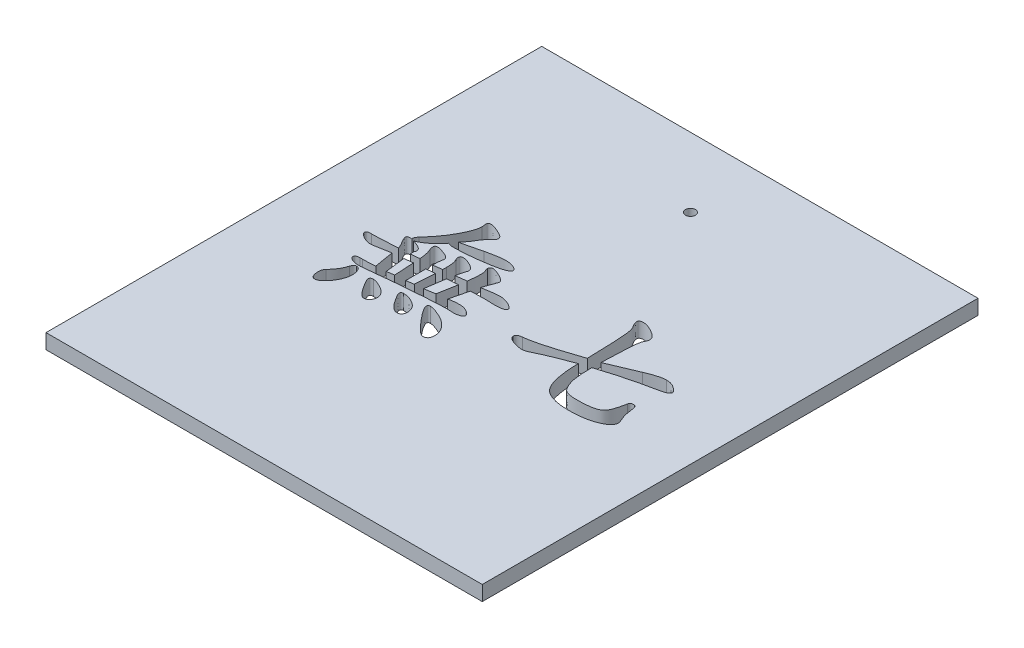
from build123d import *

# Parameters (mm, degrees)
SKETCH_1_W          = 44
SKETCH_1_H          = 1.5
EXTRUDE_1_DEPTH     = 50
CUT_EXTRUDE_1_DEPTH = 50
SKETCH_4_R          = 0.5
CUT_EXTRUDE_2_DEPTH = 1.5


with BuildPart() as part:
    # 草图1 → 凸台-拉伸1 (new body)
    with BuildSketch(Plane.XY):
        with Locations((-14.28686933, 29.867045997)):
            Rectangle(SKETCH_1_W, SKETCH_1_H)
    extrude(amount=EXTRUDE_1_DEPTH)

    # 草图3 → 切除-拉伸1 (cut)
    with BuildSketch(Plane(origin=(0, 30.617045997, 0), x_dir=(1, 0, 0), z_dir=(0, 1, 0))):
        with BuildLine():
            add(Edge.make_bspline(
                [(-23.405861887, -21.298851129), (-23.380420031, -21.296850924), (-23.312187575, -21.291486578), (-23.183397047, -21.268497079), (-23.002345834, -21.22778541), (-22.76637734, -21.175455687), (-22.477116994, -21.105205228), (-22.134721806, -21.019720235), (-21.737716997, -20.920880577), (-21.456447551, -20.846550118), (-21.306421105, -20.806902959)],
                knots=[0, 0, 0, 0, 7.6532e-05, 0.00020525, 0.000391886, 0.000633382, 0.000930282, 0.001284867, 0.001692106, 0.00215763, 0.00215763, 0.00215763, 0.00215763], degree=3))
            add(Edge.make_bspline(
                [(-21.306421105, -20.806902959), (-21.200310189, -20.782416227), (-20.996209601, -20.735316867), (-20.700555065, -20.677482905), (-20.430325523, -20.621646895), (-20.183281135, -20.582261706), (-19.961322919, -20.545167944), (-19.76312991, -20.522840732), (-19.589074754, -20.507970815), (-19.39247369, -20.501740726), (-19.172856504, -20.511554553), (-18.930074038, -20.54353493), (-18.70967313, -20.594402951), (-18.517566744, -20.67059639), (-18.359821831, -20.755796559), (-18.239155443, -20.839293983), (-18.159969986, -20.93037116), (-18.147696835, -20.998414248), (-18.142247429, -21.028626078)],
                knots=[0, 0, 0, 0, 0.00032667, 0.000628338, 0.000903735, 0.001154336, 0.001378749, 0.001578715, 0.001752489, 0.001902685, 0.002168542, 0.002410909, 0.002636661, 0.002845103, 0.003029062, 0.003172723, 0.003286365, 0.003377118, 0.003377118, 0.003377118, 0.003377118], degree=3))
            add(Edge.make_bspline(
                [(-18.142247429, -21.028626078), (-18.149339207, -21.063231783), (-18.165256083, -21.140901268), (-18.270661513, -21.237505185), (-18.422318487, -21.326546677), (-18.634570353, -21.412363253), (-18.902404858, -21.496405634), (-19.230775847, -21.575744969), (-19.617485574, -21.653532635), (-20.05080231, -21.724065837), (-20.501000476, -21.787068312), (-20.94009763, -21.849716358), (-21.355551939, -21.895964632), (-21.746280851, -21.940108062), (-22.113102868, -21.968358218), (-22.455599241, -21.992675149), (-22.773670411, -22.007167311), (-22.977800319, -22.00922641), (-23.075586825, -22.010212802)],
                knots=[0, 0, 0, 0, 0.000103753, 0.000232864, 0.000409138, 0.000634772, 0.000915986, 0.001251525, 0.001647407, 0.002099249, 0.002568288, 0.003011205, 0.003429755, 0.003822288, 0.004190743, 0.004533345, 0.004852373, 0.005145731, 0.005145731, 0.005145731, 0.005145731], degree=3))
            add(Edge.make_bspline(
                [(-23.075586825, -22.010212802), (-23.158166436, -22.009896263), (-23.309163641, -22.009317469), (-23.510545672, -21.981508182), (-23.672087695, -21.95287465), (-23.753808704, -21.905879412), (-23.789258114, -21.885493548)],
                knots=[0, 0, 0, 0, 0.000247226, 0.000452054, 0.000611149, 0.000733035, 0.000733035, 0.000733035, 0.000733035], degree=3))
            add(Edge.make_bspline(
                [(-23.789258114, -21.885493548), (-23.867134405, -21.98673215), (-24.023435674, -22.18992264), (-24.285062466, -22.475321696), (-24.576169422, -22.738583583), (-24.834024926, -22.940921254), (-25.042488924, -23.08933111), (-25.190534931, -23.183517598), (-25.326730523, -23.264655409), (-25.450806356, -23.332494465), (-25.565136501, -23.38429639), (-25.6686581, -23.420896391), (-25.761169619, -23.447002515), (-25.82004213, -23.450023365), (-25.847125811, -23.451413075)],
                knots=[0, 0, 0, 0, 0.000383069, 0.000768837, 0.001159572, 0.001559242, 0.001751482, 0.001927028, 0.002085469, 0.002227035, 0.00235109, 0.002461396, 0.002556624, 0.002637757, 0.002637757, 0.002637757, 0.002637757], degree=3))
            add(Edge.make_bspline(
                [(-25.847125811, -23.451413075), (-25.875950013, -23.449571911), (-25.928254145, -23.446230953), (-25.997455747, -23.413467254), (-26.039172493, -23.352381248), (-26.046878344, -23.272372289), (-26.032690919, -23.178857214), (-25.984930733, -23.077534097), (-25.914447158, -22.966554718), (-25.851427804, -22.896176968), (-25.817100805, -22.857841809)],
                knots=[0, 0, 0, 0, 8.6233e-05, 0.000156477, 0.000221187, 0.000298274, 0.000391693, 0.000502386, 0.000631166, 0.000785237, 0.000785237, 0.000785237, 0.000785237], degree=3))
            add(Edge.make_bspline(
                [(-25.817100805, -22.857841809), (-25.646255372, -22.665745266), (-25.312356797, -22.290313739), (-24.861508084, -21.709061797), (-24.472023846, -21.126210772), (-24.190256392, -20.641108612), (-24.00264455, -20.259829081), (-23.875412114, -19.997477417), (-23.772715387, -19.750029411), (-23.684793572, -19.521442509), (-23.621524942, -19.308438378), (-23.570888654, -19.114972192), (-23.541490843, -18.937790792), (-23.537220937, -18.825342908), (-23.535200373, -18.77213142)],
                knots=[0, 0, 0, 0, 0.000771097, 0.001507024, 0.002204608, 0.00287295, 0.003187982, 0.003479323, 0.003747418, 0.003991517, 0.004213625, 0.004413603, 0.004591309, 0.00475094, 0.00475094, 0.00475094, 0.00475094], degree=3))
            add(Edge.make_bspline(
                [(-23.535200373, -18.77213142), (-23.53664253, -18.745822575), (-23.539725466, -18.689581472), (-23.565673208, -18.595297532), (-23.579107561, -18.464428887), (-23.589510539, -18.333628792), (-23.574431008, -18.210933949), (-23.507627429, -18.135280619), (-23.400596373, -18.103321763), (-23.262695526, -18.089683074), (-23.08397472, -18.112119861), (-22.865684425, -18.173718742), (-22.604579074, -18.272844337), (-22.366621669, -18.380167617), (-22.170715564, -18.476884709), (-22.038117078, -18.550956519), (-21.925911447, -18.622330314), (-21.831146823, -18.687518286), (-21.760674762, -18.755834401), (-21.709950669, -18.820329408), (-21.672319922, -18.881409908), (-21.662363544, -18.964385958), (-21.680639618, -19.066507304), (-21.741246767, -19.184653809), (-21.832273839, -19.307086891), (-21.915220183, -19.37812627), (-21.960042383, -19.416514234)],
                knots=[0, 0, 0, 0, 7.8832e-05, 0.000168521, 0.000291994, 0.000472277, 0.000564228, 0.000652659, 0.000756464, 0.000891136, 0.001067637, 0.001292288, 0.001570719, 0.001904656, 0.002075083, 0.002226058, 0.002359976, 0.002474086, 0.002570456, 0.002652699, 0.002720901, 0.002781657, 0.002898607, 0.003026702, 0.003176827, 0.003353328, 0.003353328, 0.003353328, 0.003353328], degree=3))
            add(Edge.make_bspline(
                [(-21.960042383, -19.416514234), (-22.020669495, -19.472977798), (-22.148169024, -19.591721336), (-22.321051397, -19.805694727), (-22.497796293, -20.04988152), (-22.663106901, -20.32563997), (-22.830364383, -20.605386037), (-23.014698208, -20.862049182), (-23.202064553, -21.095156806), (-23.339196024, -21.232218962), (-23.405861887, -21.298851129)],
                knots=[0, 0, 0, 0, 0.00024826, 0.000522093, 0.000823336, 0.00115213, 0.001486067, 0.001800735, 0.002099417, 0.002381994, 0.002381994, 0.002381994, 0.002381994], degree=3))
        make_face()
        with BuildLine():
            add(Edge.make_bspline(
                [(-19.548803465, -24.255159381), (-19.532952641, -24.146675791), (-19.502536415, -23.938506091), (-19.466039455, -23.638397458), (-19.448460977, -23.363099872), (-19.440779726, -23.11503416), (-19.444312885, -22.898277878), (-19.459348098, -22.716783619), (-19.484753723, -22.571979493), (-19.532530067, -22.43654721), (-19.598204605, -22.312288874), (-19.608863999, -22.211041933), (-19.613472708, -22.167266678)],
                knots=[0, 0, 0, 0, 0.000328916, 0.000631158, 0.000906622, 0.001156157, 0.001375619, 0.001556493, 0.001702347, 0.001814833, 0.001986818, 0.002117816, 0.002117816, 0.002117816, 0.002117816], degree=3))
            add(Edge.make_bspline(
                [(-19.613472708, -22.167266678), (-19.610891854, -22.121892461), (-19.606238765, -22.040086088), (-19.549652739, -21.933098495), (-19.450851526, -21.86994858), (-19.318091439, -21.856899197), (-19.153126392, -21.879406802), (-18.94849865, -21.941409335), (-18.702423786, -22.039242977), (-18.478407841, -22.148217875), (-18.292664392, -22.243685869), (-18.166650993, -22.31797158), (-18.059670562, -22.390682323), (-17.973833514, -22.465181233), (-17.905504298, -22.536591265), (-17.855474223, -22.606699409), (-17.82223424, -22.67645188), (-17.81840196, -22.724352224), (-17.816591599, -22.746980249)],
                knots=[0, 0, 0, 0, 0.000135226, 0.000243802, 0.000348858, 0.000472655, 0.00063538, 0.000846669, 0.001112154, 0.001429312, 0.001593571, 0.001738545, 0.001867966, 0.001980948, 0.002078991, 0.002163569, 0.002239083, 0.002306696, 0.002306696, 0.002306696, 0.002306696], degree=3))
            add(Edge.make_bspline(
                [(-17.816591599, -22.746980249), (-17.821916814, -22.774942125), (-17.83386715, -22.837691475), (-17.858413938, -22.896716915), (-17.872022378, -22.929439899)],
                knots=[0, 0, 0, 0, 8.5174e-05, 0.00019114, 0.00019114, 0.00019114, 0.00019114], degree=3))
            add(Edge.make_bspline(
                [(-17.872022378, -22.929439899), (-17.907257113, -23.016981509), (-17.981324183, -23.201003064), (-18.085371784, -23.494721863), (-18.198247982, -23.815387178), (-18.267762958, -24.040871769), (-18.303920537, -24.158155516)],
                knots=[0, 0, 0, 0, 0.000283067, 0.000595036, 0.000934675, 0.001302825, 0.001302825, 0.001302825, 0.001302825], degree=3))
            add(Edge.make_bspline(
                [(-18.303920537, -24.158155516), (-18.213906044, -24.140134193), (-18.038747598, -24.10506665), (-17.783784974, -24.05939763), (-17.54440202, -24.01975304), (-17.322050959, -23.986441008), (-17.115327868, -23.964951993), (-16.92544107, -23.943965127), (-16.751137523, -23.936633879), (-16.542402346, -23.928256946), (-16.297047259, -23.941649035), (-16.016272229, -23.992396207), (-15.749315157, -24.07657804), (-15.506807311, -24.188726313), (-15.300918487, -24.311129622), (-15.149158376, -24.423348064), (-15.0396266, -24.519055974), (-15.020489933, -24.594185633), (-15.012717991, -24.624697912)],
                knots=[0, 0, 0, 0, 0.000275397, 0.000535892, 0.000777001, 0.001003355, 0.001210205, 0.001400492, 0.001576266, 0.001733388, 0.002027154, 0.0023112, 0.002587312, 0.002864283, 0.003111843, 0.003301696, 0.003437336, 0.003530095, 0.003530095, 0.003530095, 0.003530095], degree=3))
            add(Edge.make_bspline(
                [(-15.012717991, -24.624697912), (-15.016469248, -24.652582209), (-15.024170226, -24.709826052), (-15.085851908, -24.783203216), (-15.17841432, -24.8397297), (-15.303665874, -24.887892829), (-15.464918579, -24.922165711), (-15.66016159, -24.949316932), (-15.890897835, -24.964871631), (-16.055871659, -24.965944914), (-16.144429744, -24.966521054)],
                knots=[0, 0, 0, 0, 8.2921e-05, 0.00017023, 0.000275285, 0.000406954, 0.000570546, 0.00076881, 0.000998033, 0.001263679, 0.001263679, 0.001263679, 0.001263679], degree=3))
            Line((-16.144429744, -24.966521054), (-17.098301078, -24.936496048))
            add(Edge.make_bspline(
                [(-17.098301078, -24.936496048), (-17.200697454, -24.9369836), (-17.415519423, -24.938006457), (-17.752741509, -24.945465461), (-18.120758672, -24.956968868), (-18.376298104, -24.967803348), (-18.509476345, -24.973449901)],
                knots=[0, 0, 0, 0, 0.000307188, 0.000644463, 0.001011873, 0.001411764, 0.001411764, 0.001411764, 0.001411764], degree=3))
            Line((-18.509476345, -24.973449901), (-18.964470662, -26.828071406))
            add(Edge.make_bspline(
                [(-18.964470662, -26.828071406), (-18.883948938, -26.805949739), (-18.721250947, -26.761251854), (-18.467618602, -26.718086665), (-18.205139993, -26.694195146), (-17.938113035, -26.682543258), (-17.675636452, -26.69827079), (-17.42706606, -26.739633724), (-17.199630567, -26.816792742), (-17.001161215, -26.921900614), (-16.836745389, -27.035799307), (-16.712534846, -27.146554774), (-16.63158692, -27.251988391), (-16.603140752, -27.358688707), (-16.625143289, -27.458382695), (-16.700804214, -27.537500586), (-16.810004463, -27.607440706), (-17.00891576, -27.672831977), (-17.273984879, -27.73193018), (-17.590128006, -27.737296571), (-17.880849106, -27.70844898), (-18.068264825, -27.708169479), (-18.15841474, -27.708035034)],
                knots=[0, 0, 0, 0, 0.000250399, 0.000505943, 0.000770462, 0.001040845, 0.001306943, 0.001557937, 0.00179458, 0.002023919, 0.002229592, 0.002393037, 0.002522458, 0.002622173, 0.002714616, 0.002814572, 0.002941411, 0.003101443, 0.003438908, 0.003753151, 0.004044749, 0.004315013, 0.004315013, 0.004315013, 0.004315013], degree=3))
            add(Edge.make_bspline(
                [(-18.15841474, -27.708035034), (-18.24156694, -27.708438532), (-18.424083298, -27.709324198), (-18.720529838, -27.719368458), (-19.063834267, -27.736305491), (-19.454146346, -27.757360358), (-19.892403554, -27.78136466), (-20.377202836, -27.817942666), (-20.908448026, -27.856698304), (-21.471242537, -27.899607467), (-22.037199554, -27.943875519), (-22.576617116, -27.991680253), (-23.075760796, -28.031661858), (-23.533087598, -28.073216139), (-23.948712319, -28.115185201), (-24.323649828, -28.154391831), (-24.657806493, -28.191115704), (-24.954206339, -28.225835729), (-25.217976289, -28.259877899), (-25.456125158, -28.286125045), (-25.670512247, -28.313800062), (-25.862589535, -28.330104995), (-26.031630873, -28.348827035), (-26.178178385, -28.356169199), (-26.302035731, -28.364414873), (-26.495102585, -28.369352893), (-26.769682365, -28.343054258), (-27.054433444, -28.255070603), (-27.256261902, -28.16160023), (-27.368033832, -28.084446117), (-27.443707622, -28.001210287), (-27.464292725, -27.907038624), (-27.453003909, -27.826301151), (-27.429977838, -27.756034089), (-27.381952111, -27.70321983), (-27.290898789, -27.661289315), (-27.155328957, -27.633078214), (-27.04133921, -27.629230341), (-26.981147179, -27.627198481)],
                knots=[0, 0, 0, 0, 0.000249449, 0.000547533, 0.000889738, 0.001280616, 0.001720178, 0.002206433, 0.002739094, 0.003318163, 0.003899714, 0.004442134, 0.004942741, 0.00540193, 0.005819735, 0.006195947, 0.006532874, 0.006828234, 0.007091216, 0.007330715, 0.007547007, 0.007739594, 0.007908969, 0.008057073, 0.008179678, 0.008281328, 0.008636393, 0.009000969, 0.009170375, 0.009301129, 0.009407897, 0.009498091, 0.009579453, 0.009651089, 0.009716496, 0.00978674, 0.009948083, 0.010128603, 0.010128603, 0.010128603, 0.010128603], degree=3))
            Line((-26.981147179, -27.627198481), (-26.71554136, -27.627198481))
            add(Edge.make_bspline(
                [(-26.71554136, -27.627198481), (-26.623908615, -27.626268662), (-26.432080458, -27.624322136), (-26.132611385, -27.608745416), (-25.808322155, -27.58897068), (-25.584553509, -27.568526709), (-25.468348816, -27.557910006)],
                knots=[0, 0, 0, 0, 0.000274883, 0.000575453, 0.000899466, 0.001249509, 0.001249509, 0.001249509, 0.001249509], degree=3))
            Line((-25.468348816, -27.557910006), (-25.791695031, -25.594736557))
            add(Edge.make_bspline(
                [(-25.791695031, -25.594736557), (-25.918051343, -25.613397041), (-26.154098205, -25.648256783), (-26.483140771, -25.705654759), (-26.764474324, -25.752742599), (-27.000134093, -25.807657409), (-27.205050695, -25.851955568), (-27.391635195, -25.882150447), (-27.565825188, -25.900384841), (-27.732769721, -25.911060013), (-27.905055042, -25.893305067), (-28.090178048, -25.845054803), (-28.295462916, -25.7664247), (-28.50818107, -25.664249394), (-28.70259581, -25.550313784), (-28.853431398, -25.438343496), (-28.950689828, -25.330386761), (-28.985078208, -25.221631145), (-28.976169871, -25.133764777), (-28.953636245, -25.065148093), (-28.915403861, -25.012890982), (-28.828788761, -24.978183461), (-28.684653901, -24.965391454), (-28.560152926, -24.963193171), (-28.487016695, -24.961901822)],
                knots=[0, 0, 0, 0, 0.000383153, 0.000715769, 0.001002087, 0.001238572, 0.001441503, 0.001630976, 0.00180518, 0.001967001, 0.002131779, 0.002322235, 0.002539302, 0.002790329, 0.003029572, 0.003213908, 0.003353501, 0.003457254, 0.003545292, 0.003613962, 0.003673117, 0.003732001, 0.003886175, 0.004105698, 0.004105698, 0.004105698, 0.004105698], degree=3))
            add(Edge.make_bspline(
                [(-28.487016695, -24.961901822), (-28.419262203, -24.961418959), (-28.272175647, -24.960370723), (-28.034321967, -24.952109245), (-27.761725441, -24.943767196), (-27.454550932, -24.929343766), (-27.112709992, -24.911020021), (-26.736341397, -24.887001707), (-26.325121801, -24.862516343), (-26.039578225, -24.842814369), (-25.891008512, -24.832563336)],
                knots=[0, 0, 0, 0, 0.000203259, 0.000441251, 0.000713942, 0.001021433, 0.001363755, 0.00174093, 0.002152826, 0.002599592, 0.002599592, 0.002599592, 0.002599592], degree=3))
            add(Edge.make_bspline(
                [(-25.891008512, -24.832563336), (-25.940727358, -24.70693629), (-26.043221284, -24.447959863), (-26.224424067, -24.152823148), (-26.367143771, -23.926956811), (-26.439338754, -23.774979352), (-26.49100632, -23.648847846), (-26.508504376, -23.542433142), (-26.493008306, -23.452506907), (-26.431839729, -23.388567113), (-26.337171828, -23.357225188), (-26.210320027, -23.347662052), (-26.046779003, -23.367234573), (-25.844831124, -23.416144178), (-25.60176979, -23.493449604), (-25.379760445, -23.579737662), (-25.195494298, -23.656890389), (-25.072997925, -23.722774822), (-24.966569325, -23.786158897), (-24.881597483, -23.855865608), (-24.812533578, -23.925227128), (-24.762224125, -23.997195917), (-24.732511441, -24.07358677), (-24.728794733, -24.125586961), (-24.726962137, -24.151226669)],
                knots=[0, 0, 0, 0, 0.000404559, 0.000833986, 0.001035995, 0.001205402, 0.0013384, 0.001443253, 0.001526174, 0.00160137, 0.001695725, 0.001818678, 0.001981158, 0.002187336, 0.00244154, 0.002745656, 0.002901842, 0.003040284, 0.003162693, 0.00327271, 0.003369079, 0.003455559, 0.003534492, 0.003611267, 0.003611267, 0.003611267, 0.003611267], degree=3))
            add(Edge.make_bspline(
                [(-24.726962137, -24.151226669), (-24.728243996, -24.173004771), (-24.731195892, -24.22315592), (-24.763639172, -24.301521258), (-24.786785429, -24.403979772), (-24.793278483, -24.523787381), (-24.790559246, -24.646369829), (-24.784973458, -24.726333144), (-24.782392917, -24.763274862)],
                knots=[0, 0, 0, 0, 6.5039e-05, 0.000149774, 0.000251738, 0.000379102, 0.000508461, 0.000619539, 0.000619539, 0.000619539, 0.000619539], degree=3))
            Line((-24.782392917, -24.763274862), (-23.886261978, -24.67550946))
            add(Edge.make_bspline(
                [(-23.886261978, -24.67550946), (-23.89809116, -24.548977254), (-23.9208609, -24.305418118), (-23.986328853, -23.957948342), (-24.071104185, -23.64226307), (-24.15069866, -23.449192788), (-24.188821651, -23.356718826)],
                knots=[0, 0, 0, 0, 0.000381052, 0.000733478, 0.001059617, 0.001359422, 0.001359422, 0.001359422, 0.001359422], degree=3))
            add(Edge.make_bspline(
                [(-24.188821651, -23.356718826), (-24.209681353, -23.298018781), (-24.252622038, -23.177181954), (-24.268364536, -23.017612158), (-24.255506884, -22.892421365), (-24.203006374, -22.817532654), (-24.115771322, -22.779096719), (-24.000151276, -22.76770956), (-23.850625447, -22.785727629), (-23.661450124, -22.82922504), (-23.431945622, -22.903219511), (-23.218450849, -22.979401725), (-23.039876435, -23.047555836), (-22.920979942, -23.10787393), (-22.818432463, -23.16786077), (-22.736298227, -23.232352034), (-22.668279846, -23.297068504), (-22.622313753, -23.366820601), (-22.591025399, -23.438897791), (-22.587639564, -23.488830372), (-22.585948271, -23.513772702)],
                knots=[0, 0, 0, 0, 0.000186279, 0.000383464, 0.000477252, 0.000556725, 0.00064452, 0.000753953, 0.000902417, 0.001094059, 0.001335864, 0.001625147, 0.001774399, 0.001908675, 0.002024732, 0.002130067, 0.002221523, 0.002304797, 0.002379423, 0.002453906, 0.002453906, 0.002453906, 0.002453906], degree=3))
            add(Edge.make_bspline(
                [(-22.585948271, -23.513772702), (-22.590760985, -23.544692974), (-22.601207923, -23.611811465), (-22.619802551, -23.67715741), (-22.629830971, -23.712399663)],
                knots=[0, 0, 0, 0, 9.3789e-05, 0.000203586, 0.000203586, 0.000203586, 0.000203586], degree=3))
            add(Edge.make_bspline(
                [(-22.629830971, -23.712399663), (-22.639780935, -23.767727247), (-22.661924687, -23.890859385), (-22.680984538, -24.096195535), (-22.6917143, -24.339722939), (-22.693526634, -24.514591677), (-22.694500214, -24.608530602)],
                knots=[0, 0, 0, 0, 0.000168586, 0.00037519, 0.000617975, 0.000899786, 0.000899786, 0.000899786, 0.000899786], degree=3))
            Line((-22.694500214, -24.608530602), (-21.807607739, -24.483811347))
            Line((-21.807607739, -24.483811347), (-21.78451158, -24.121201663))
            add(Edge.make_bspline(
                [(-21.78451158, -24.121201663), (-21.78608454, -23.997100985), (-21.788994731, -23.767497808), (-21.825357581, -23.452031377), (-21.88203146, -23.19019446), (-21.950034866, -23.044098591), (-21.980828925, -22.977941831)],
                knots=[0, 0, 0, 0, 0.000372027, 0.000688301, 0.000952144, 0.001170497, 0.001170497, 0.001170497, 0.001170497], degree=3))
            add(Edge.make_bspline(
                [(-21.980828925, -22.977941831), (-22.006565217, -22.918780254), (-22.05774129, -22.801138707), (-22.08215018, -22.643586521), (-22.061167849, -22.519243809), (-21.990240441, -22.450175763), (-21.882812612, -22.41653755), (-21.74277335, -22.408223647), (-21.56830439, -22.42468363), (-21.366141085, -22.481953635), (-21.135582382, -22.568432947), (-20.8941205, -22.684388288), (-20.668995531, -22.815786352), (-20.491471577, -22.952954229), (-20.377556477, -23.10432214), (-20.360462371, -23.21370332), (-20.352549771, -23.264334193)],
                knots=[0, 0, 0, 0, 0.000193015, 0.000383807, 0.000471755, 0.000558327, 0.000664292, 0.00080335, 0.000977324, 0.001187397, 0.001431496, 0.001715589, 0.001990083, 0.002211578, 0.002387746, 0.002539567, 0.002539567, 0.002539567, 0.002539567], degree=3))
            add(Edge.make_bspline(
                [(-20.352549771, -23.264334193), (-20.355504923, -23.293319317), (-20.361918227, -23.356223166), (-20.391844073, -23.412064242), (-20.407980551, -23.442174612)],
                knots=[0, 0, 0, 0, 8.6572e-05, 0.00018788, 0.00018788, 0.00018788, 0.00018788], degree=3))
            add(Edge.make_bspline(
                [(-20.407980551, -23.442174612), (-20.422190269, -23.48826768), (-20.457252064, -23.602000105), (-20.50834971, -23.808205253), (-20.573357073, -24.079723647), (-20.617101978, -24.283531806), (-20.641251749, -24.396045946)],
                knots=[0, 0, 0, 0, 0.000144679, 0.000356987, 0.00063709, 0.000982298, 0.000982298, 0.000982298, 0.000982298], degree=3))
            Line((-20.641251749, -24.396045946), (-19.548803465, -24.255159381))
        make_face()
        with BuildLine():
            Line((-20.006107398, -26.948171429), (-19.66197464, -25.031190297))
            add(Edge.make_bspline(
                [(-19.66197464, -25.031190297), (-19.846852919, -25.03711053), (-20.222458997, -25.049138311), (-20.596715197, -25.083188524), (-20.786757545, -25.100478772)],
                knots=[0, 0, 0, 0, 0.000554789, 0.001127131, 0.001127131, 0.001127131, 0.001127131], degree=3))
            Line((-20.786757545, -25.100478772), (-21.082388371, -27.126011847))
            add(Edge.make_bspline(
                [(-21.082388371, -27.126011847), (-20.974616994, -27.109016054), (-20.770578638, -27.076838737), (-20.482986952, -27.032398257), (-20.232575775, -26.986703882), (-20.077728097, -26.96035733), (-20.006107398, -26.948171429)],
                knots=[0, 0, 0, 0, 0.000327314, 0.000619688, 0.000872957, 0.001090907, 0.001090907, 0.001090907, 0.001090907], degree=3))
        make_face(mode=Mode.SUBTRACT)
        with BuildLine():
            add(Edge.make_bspline(
                [(-21.807607739, -25.185934557), (-21.913104338, -25.19649458), (-22.10260583, -25.215463345), (-22.355837321, -25.243668417), (-22.546219713, -25.265255952), (-22.652184841, -25.281193332), (-22.694500214, -25.287557653)],
                knots=[0, 0, 0, 0, 0.000318065, 0.000571334, 0.000764419, 0.000892784, 0.000892784, 0.000892784, 0.000892784], degree=3))
            Line((-22.694500214, -25.287557653), (-22.694500214, -27.313090729))
            add(Edge.make_bspline(
                [(-22.694500214, -27.313090729), (-22.612160295, -27.299006164), (-22.460700772, -27.273098421), (-22.252820864, -27.240779269), (-22.084295162, -27.216659088), (-21.984708922, -27.206590957), (-21.941565456, -27.202229169)],
                knots=[0, 0, 0, 0, 0.000250601, 0.000460967, 0.000631143, 0.000761222, 0.000761222, 0.000761222, 0.000761222], degree=3))
            Line((-21.941565456, -27.202229169), (-21.807607739, -25.185934557))
        make_face(mode=Mode.SUBTRACT)
        with BuildLine():
            add(Edge.make_bspline(
                [(-23.846998509, -25.375323054), (-23.933278242, -25.38329586), (-24.096013449, -25.398333645), (-24.326021051, -25.42716872), (-24.527937156, -25.453656238), (-24.653098633, -25.474340219), (-24.710794827, -25.483874998)],
                knots=[0, 0, 0, 0, 0.000259922, 0.000490247, 0.000695374, 0.000870799, 0.000870799, 0.000870799, 0.000870799], degree=3))
            Line((-24.710794827, -25.483874998), (-24.470594781, -27.502479226))
            add(Edge.make_bspline(
                [(-24.470594781, -27.502479226), (-24.417456637, -27.494116414), (-24.317307868, -27.47835513), (-24.177400315, -27.454719269), (-24.055629142, -27.436303023), (-23.953120304, -27.420855659), (-23.870219956, -27.40621536), (-23.806206964, -27.396945605), (-23.761433364, -27.390736658), (-23.737668692, -27.386276651), (-23.729208102, -27.384688819)],
                knots=[0, 0, 0, 0, 0.000161376, 0.000304143, 0.000425656, 0.000530839, 0.000615132, 0.000678172, 0.000724881, 0.000750703, 0.000750703, 0.000750703, 0.000750703], degree=3))
            Line((-23.729208102, -27.384688819), (-23.846998509, -25.375323054))
        make_face(mode=Mode.SUBTRACT)
        with BuildLine():
            add(Edge.make_bspline(
                [(-19.188503397, -28.310844764), (-19.158422959, -28.311745734), (-19.093263004, -28.313697408), (-18.98900953, -28.33141927), (-18.871435525, -28.359898489), (-18.74044363, -28.396834754), (-18.595101415, -28.443205403), (-18.437879211, -28.503702697), (-18.265865843, -28.574101061), (-18.021052403, -28.674938504), (-17.722566084, -28.820825771), (-17.39535011, -29.026266151), (-17.107764798, -29.256478205), (-16.862431156, -29.509168338), (-16.664591748, -29.781285625), (-16.518498952, -30.069825655), (-16.435525329, -30.375266521), (-16.411492339, -30.634790147), (-16.422646695, -30.834763699), (-16.446488568, -30.966677115), (-16.488088382, -31.079589306), (-16.549362683, -31.172592789), (-16.629137539, -31.24497038), (-16.725334948, -31.297957329), (-16.839404809, -31.327902371), (-16.921048597, -31.330463906), (-16.96434336, -31.331822259)],
                knots=[0, 0, 0, 0, 9.0193e-05, 0.000195376, 0.000316383, 0.000453119, 0.000603582, 0.000773884, 0.000958306, 0.001161198, 0.001568162, 0.001953266, 0.002317937, 0.002670756, 0.003006637, 0.003323736, 0.003635286, 0.003950614, 0.004101023, 0.0042351, 0.004351341, 0.004459598, 0.004565865, 0.004671301, 0.004786156, 0.004915824, 0.004915824, 0.004915824, 0.004915824], degree=3))
            add(Edge.make_bspline(
                [(-16.96434336, -31.331822259), (-16.995531899, -31.327891326), (-17.066960244, -31.318888658), (-17.177922294, -31.264546826), (-17.305436767, -31.181264372), (-17.455866136, -31.066049065), (-17.628129241, -30.90714991), (-17.828574005, -30.702334224), (-18.061550246, -30.450136804), (-18.31486439, -30.162247378), (-18.569634945, -29.866653657), (-18.793339434, -29.581395366), (-18.990713426, -29.330950041), (-19.147838979, -29.105540164), (-19.268026332, -28.908125658), (-19.359613393, -28.743435695), (-19.41103398, -28.606442055), (-19.437373183, -28.497668718), (-19.421953331, -28.410686645), (-19.372046123, -28.346157659), (-19.287124951, -28.316071391), (-19.224046317, -28.312728425), (-19.188503397, -28.310844764)],
                knots=[0, 0, 0, 0, 9.3789e-05, 0.000214796, 0.000365364, 0.000551528, 0.000782086, 0.001067891, 0.0014111, 0.00181197, 0.002218304, 0.002581531, 0.002899362, 0.003174855, 0.003404996, 0.003593027, 0.00373846, 0.003844022, 0.003924196, 0.003994894, 0.004077687, 0.004184555, 0.004184555, 0.004184555, 0.004184555], degree=3))
        make_face()
        with BuildLine():
            add(Edge.make_bspline(
                [(-26.459174004, -28.530258267), (-26.410032705, -28.534167029), (-26.315641336, -28.54167504), (-26.184890179, -28.60297581), (-26.081974475, -28.70868908), (-25.987467524, -28.897941817), (-25.901008101, -29.15528116), (-25.888072503, -29.371738754), (-25.881770048, -29.477200754)],
                knots=[0, 0, 0, 0, 0.000146983, 0.000282327, 0.000422778, 0.000580932, 0.000913268, 0.001229035, 0.001229035, 0.001229035, 0.001229035], degree=3))
            add(Edge.make_bspline(
                [(-25.881770048, -29.477200754), (-25.888619955, -29.607218576), (-25.902444204, -29.86961613), (-26.011622424, -30.259078282), (-26.18144495, -30.646246189), (-26.377982725, -30.953554339), (-26.551964615, -31.187098993), (-26.685150713, -31.340269829), (-26.812649085, -31.473085681), (-26.940803687, -31.579971908), (-27.06502787, -31.665610552), (-27.189645285, -31.722966216), (-27.310364686, -31.764184054), (-27.391950164, -31.768537618), (-27.431522265, -31.770649265)],
                knots=[0, 0, 0, 0, 0.000389559, 0.000786195, 0.001205026, 0.001654268, 0.001876916, 0.002078329, 0.002262882, 0.002428483, 0.002578377, 0.002713721, 0.002839378, 0.002957733, 0.002957733, 0.002957733, 0.002957733], degree=3))
            add(Edge.make_bspline(
                [(-27.431522265, -31.770649265), (-27.468996042, -31.767675576), (-27.542745939, -31.761823238), (-27.645574928, -31.710311461), (-27.724781045, -31.620918493), (-27.812010992, -31.464004213), (-27.872308796, -31.222219968), (-27.898028747, -30.965774721), (-27.882844211, -30.755062571), (-27.843065068, -30.607100507), (-27.77875358, -30.472842874), (-27.713669304, -30.400466468), (-27.680960773, -30.364093229)],
                knots=[0, 0, 0, 0, 0.000112034, 0.000220488, 0.000334855, 0.0004652, 0.00075612, 0.001073748, 0.001236014, 0.001386725, 0.001531329, 0.001677421, 0.001677421, 0.001677421, 0.001677421], degree=3))
            add(Edge.make_bspline(
                [(-27.680960773, -30.364093229), (-27.57683669, -30.246776007), (-27.374962103, -30.019322714), (-27.122169477, -29.655206347), (-26.922277151, -29.285274099), (-26.833159398, -29.028197119), (-26.789449066, -28.902106414)],
                knots=[0, 0, 0, 0, 0.000470215, 0.000911648, 0.001326975, 0.001726778, 0.001726778, 0.001726778, 0.001726778], degree=3))
            add(Edge.make_bspline(
                [(-26.789449066, -28.902106414), (-26.770824907, -28.847207565), (-26.737121689, -28.747859839), (-26.662580408, -28.626517711), (-26.568890961, -28.543747126), (-26.495143639, -28.534680458), (-26.459174004, -28.530258267)],
                knots=[0, 0, 0, 0, 0.000173283, 0.000313581, 0.000425401, 0.000531869, 0.000531869, 0.000531869, 0.000531869], degree=3))
        make_face()
        with BuildLine():
            add(Edge.make_bspline(
                [(-19.832886211, -29.978387387), (-19.833797718, -30.024686104), (-19.835497774, -30.111038074), (-19.858646375, -30.232165237), (-19.897462863, -30.333557396), (-19.949238325, -30.419908578), (-20.020220063, -30.485018075), (-20.106344829, -30.532930116), (-20.207723042, -30.559679934), (-20.320962069, -30.568104613), (-20.443955637, -30.558073029), (-20.56949485, -30.515411857), (-20.698898563, -30.452889648), (-20.82716564, -30.360316061), (-20.959787555, -30.245732829), (-21.095776322, -30.10736893), (-21.231876692, -29.941828505), (-21.364380191, -29.7576755), (-21.492408307, -29.572198886), (-21.604828287, -29.397615482), (-21.699400077, -29.242297854), (-21.779637252, -29.1077054), (-21.841447692, -28.991400463), (-21.887172518, -28.894061048), (-21.913763279, -28.814906041), (-21.927603371, -28.7383152), (-21.914997309, -28.65976609), (-21.859826958, -28.589462102), (-21.770889814, -28.549302768), (-21.702576045, -28.547456835), (-21.664411558, -28.546425578)],
                knots=[0, 0, 0, 0, 0.00013875, 0.000258783, 0.000367728, 0.000463207, 0.000557986, 0.000653102, 0.00075621, 0.000869758, 0.000992711, 0.001123465, 0.001264975, 0.001422588, 0.001596194, 0.001790545, 0.002003756, 0.002238429, 0.002470979, 0.00267983, 0.002861249, 0.003016527, 0.003149806, 0.003256274, 0.003338808, 0.003399565, 0.003488807, 0.003567808, 0.003657675, 0.003771434, 0.003771434, 0.003771434, 0.003771434], degree=3))
            add(Edge.make_bspline(
                [(-21.664411558, -28.546425578), (-21.560870474, -28.551698597), (-21.351233727, -28.562374731), (-21.038567215, -28.638602153), (-20.731817593, -28.769723012), (-20.48371115, -28.911945126), (-20.297809244, -29.048639636), (-20.172130006, -29.158222821), (-20.067574572, -29.277609652), (-19.979514708, -29.402670532), (-19.916683471, -29.538202241), (-19.865462179, -29.678093269), (-19.838399035, -29.826451146), (-19.834733184, -29.927483863), (-19.832886211, -29.978387387)],
                knots=[0, 0, 0, 0, 0.00031053, 0.000628721, 0.000958996, 0.001308786, 0.00148386, 0.001650729, 0.001807817, 0.001959004, 0.002107755, 0.002254575, 0.002404966, 0.00255768, 0.00255768, 0.00255768, 0.00255768], degree=3))
        make_face()
        with BuildLine():
            add(Edge.make_bspline(
                [(-22.639069434, -30.243993207), (-22.64087205, -30.286476821), (-22.644482903, -30.37157656), (-22.673037503, -30.497050593), (-22.721112136, -30.619246374), (-22.7831281, -30.737148072), (-22.866414461, -30.84626207), (-22.987954718, -30.918037841), (-23.13195962, -30.966697319), (-23.238318678, -30.969844808), (-23.295000328, -30.971522191)],
                knots=[0, 0, 0, 0, 0.000127364, 0.000255126, 0.000383803, 0.000520207, 0.000654761, 0.000788679, 0.000936945, 0.001106115, 0.001106115, 0.001106115, 0.001106115], degree=3))
            add(Edge.make_bspline(
                [(-23.295000328, -30.971522191), (-23.326365917, -30.968009086), (-23.395728638, -30.960240111), (-23.497614915, -30.90128275), (-23.612173031, -30.820820012), (-23.735230151, -30.700662671), (-23.87097069, -30.544950554), (-24.021505567, -30.34802923), (-24.188571948, -30.111481079), (-24.361585652, -29.848332387), (-24.52049056, -29.589306113), (-24.641057475, -29.36282777), (-24.718668436, -29.185790514), (-24.750276071, -29.049988097), (-24.733138446, -28.943600316), (-24.667739277, -28.868958527), (-24.561709778, -28.83474121), (-24.483072897, -28.830573664), (-24.43826016, -28.828198708)],
                knots=[0, 0, 0, 0, 9.3789e-05, 0.000207407, 0.000346483, 0.000514768, 0.000720959, 0.000966268, 0.001257847, 0.001589669, 0.001910905, 0.00216918, 0.002358751, 0.002490136, 0.002582086, 0.002670518, 0.002772167, 0.00290684, 0.00290684, 0.00290684, 0.00290684], degree=3))
            add(Edge.make_bspline(
                [(-24.43826016, -28.828198708), (-24.365368659, -28.833911572), (-24.203802026, -28.84657434), (-23.94815688, -28.93510656), (-23.654173206, -29.065630277), (-23.392106277, -29.209688893), (-23.179717023, -29.345316749), (-23.034765781, -29.455359869), (-22.914299838, -29.574367116), (-22.813294626, -29.696391847), (-22.735703224, -29.825735162), (-22.679504903, -29.960091822), (-22.646222303, -30.100742278), (-22.641461281, -30.196091546), (-22.639069434, -30.243993207)],
                knots=[0, 0, 0, 0, 0.000218585, 0.000484502, 0.000805073, 0.00118442, 0.001379812, 0.001560907, 0.001729128, 0.001886759, 0.002034899, 0.002179872, 0.002322171, 0.002465832, 0.002465832, 0.002465832, 0.002465832], degree=3))
        make_face()
        with BuildLine():
            add(Edge.make_bspline(
                [(-5.695727766, -25.536996162), (-5.695359537, -25.670183301), (-5.694648522, -25.927355342), (-5.687104316, -26.300224765), (-5.665261148, -26.645154403), (-5.638413902, -26.964165923), (-5.602440522, -27.255600449), (-5.556156202, -27.520751971), (-5.502155904, -27.75872165), (-5.436349158, -27.970123553), (-5.366592152, -28.158842005), (-5.294048341, -28.327785849), (-5.214224924, -28.475287881), (-5.136606007, -28.606549299), (-5.054141503, -28.718394369), (-4.965478403, -28.809018948), (-4.875258964, -28.882198317), (-4.746021348, -28.955966789), (-4.557542784, -29.015558972), (-4.30289435, -29.068013514), (-4.005055859, -29.098697253), (-3.676405359, -29.107970916), (-3.337486467, -29.102170102), (-3.011622529, -29.089405213), (-2.708911537, -29.065947199), (-2.430360188, -29.035357976), (-2.176849932, -28.991196948), (-1.949994923, -28.940072), (-1.751921234, -28.875324049), (-1.577973901, -28.799124525), (-1.424576862, -28.700686569), (-1.294636777, -28.569869521), (-1.17938897, -28.412241033), (-1.080791808, -28.217712168), (-0.994454289, -27.976850054), (-0.903931438, -27.681946581), (-0.815470434, -27.323899308), (-0.761435001, -27.063085987), (-0.732363365, -26.922765655)],
                knots=[0, 0, 0, 0, 0.00039957, 0.000771533, 0.001118599, 0.001436227, 0.001731867, 0.001999185, 0.002243448, 0.002463347, 0.002662845, 0.002846934, 0.003014314, 0.003165624, 0.003304201, 0.003429964, 0.003545028, 0.003651597, 0.003874388, 0.00413394, 0.004431334, 0.004771043, 0.005119826, 0.005448084, 0.005749221, 0.006030549, 0.006288369, 0.006520861, 0.006727556, 0.006912585, 0.007089387, 0.007270674, 0.007462386, 0.007673118, 0.007922354, 0.008229194, 0.008598342, 0.009028235, 0.009028235, 0.009028235, 0.009028235], degree=3))
            add(Edge.make_bspline(
                [(-0.732363365, -26.922765655), (-0.72080617, -26.88054745), (-0.699340637, -26.802134285), (-0.62082218, -26.708088697), (-0.512127295, -26.65269329), (-0.385049335, -26.640775138), (-0.254376565, -26.65697311), (-0.145545088, -26.735433158), (-0.070231061, -26.858248923), (-0.053414742, -26.957726334), (-0.04409785, -27.012840672)],
                knots=[0, 0, 0, 0, 0.000130038, 0.000241523, 0.000356193, 0.000486538, 0.000620196, 0.000741292, 0.00087521, 0.001041582, 0.001041582, 0.001041582, 0.001041582], degree=3))
            add(Edge.make_bspline(
                [(-0.04409785, -27.012840672), (-0.024282182, -27.173392356), (0.013669286, -27.480885012), (0.107983095, -27.916491779), (0.218935544, -28.309279247), (0.320767464, -28.548053188), (0.369323382, -28.661906369)],
                knots=[0, 0, 0, 0, 0.000485047, 0.000928974, 0.001336024, 0.00170701, 0.00170701, 0.00170701, 0.00170701], degree=3))
            add(Edge.make_bspline(
                [(0.369323382, -28.661906369), (0.386320726, -28.698540417), (0.41768083, -28.766130246), (0.449809306, -28.865610728), (0.472996214, -28.952631092), (0.476340295, -29.008232057), (0.477875326, -29.033754516)],
                knots=[0, 0, 0, 0, 0.000121007, 0.000223258, 0.000313452, 0.000389983, 0.000389983, 0.000389983, 0.000389983], degree=3))
            add(Edge.make_bspline(
                [(0.477875326, -29.033754516), (0.474499761, -29.079546282), (0.467638546, -29.172623207), (0.418559581, -29.309132142), (0.338611917, -29.440443665), (0.222742433, -29.562665385), (0.082478538, -29.686297969), (-0.093689883, -29.800794944), (-0.300261752, -29.910283721), (-0.533969793, -30.018527801), (-0.79313855, -30.116955606), (-1.073704336, -30.201247347), (-1.371485112, -30.276474145), (-1.689784545, -30.332575061), (-2.025749672, -30.37816598), (-2.380749548, -30.414150119), (-2.754648809, -30.431060293), (-3.010402385, -30.434123581), (-3.141292667, -30.43569132)],
                knots=[0, 0, 0, 0, 0.000137223, 0.000278921, 0.000430232, 0.000595382, 0.000782018, 0.000990204, 0.001223749, 0.001483137, 0.001762381, 0.002054618, 0.002361588, 0.002683231, 0.003023584, 0.003378649, 0.003753263, 0.004145959, 0.004145959, 0.004145959, 0.004145959], degree=3))
            add(Edge.make_bspline(
                [(-3.141292667, -30.43569132), (-3.323876319, -30.433042391), (-3.672887238, -30.427978931), (-4.170524176, -30.377735562), (-4.616828213, -30.293539055), (-5.012395765, -30.1769455), (-5.358426563, -30.028508216), (-5.652468866, -29.842941128), (-5.893147863, -29.62050711), (-6.082384106, -29.359482449), (-6.231402087, -29.061578754), (-6.359940308, -28.726880289), (-6.47069853, -28.351597543), (-6.558384193, -27.933372488), (-6.632844257, -27.474983012), (-6.683918472, -26.973680435), (-6.719586549, -26.43131854), (-6.725212017, -26.055182709), (-6.728126038, -25.860342377)],
                knots=[0, 0, 0, 0, 0.000547618, 0.001046778, 0.001498383, 0.001908306, 0.002281643, 0.002624409, 0.002946341, 0.003258618, 0.003586071, 0.00394292, 0.004333156, 0.004758533, 0.005224051, 0.005725748, 0.006269612, 0.00685411, 0.00685411, 0.00685411, 0.00685411], degree=3))
            add(Edge.make_bspline(
                [(-6.728126038, -25.860342377), (-6.91755422, -25.931833899), (-7.282083065, -26.069409636), (-7.8063474, -26.269215042), (-8.285668532, -26.459472878), (-8.720682144, -26.63650338), (-9.112825269, -26.80069919), (-9.459982369, -26.952562564), (-9.764234329, -27.090153203), (-9.949511193, -27.182478363), (-10.035495895, -27.225325328)],
                knots=[0, 0, 0, 0, 0.000607411, 0.001168881, 0.001683117, 0.002154471, 0.002577843, 0.002958453, 0.003291238, 0.003579423, 0.003579423, 0.003579423, 0.003579423], degree=3))
            add(Edge.make_bspline(
                [(-10.035495895, -27.225325328), (-10.110265267, -27.2629716), (-10.253153508, -27.334915625), (-10.469486311, -27.415397913), (-10.676157927, -27.462178741), (-10.878450167, -27.48055395), (-11.08703023, -27.46297002), (-11.314692795, -27.422422637), (-11.567777436, -27.357066028), (-11.789444125, -27.284387514), (-11.967461051, -27.218236143), (-12.084595731, -27.158542775), (-12.188110795, -27.103812889), (-12.269359717, -27.039343054), (-12.336198774, -26.976435933), (-12.38064951, -26.906963316), (-12.411344262, -26.836703653), (-12.414941172, -26.787564409), (-12.416709807, -26.763402163)],
                knots=[0, 0, 0, 0, 0.000251027, 0.000479725, 0.000690407, 0.000885088, 0.001086501, 0.001316224, 0.001578383, 0.001869807, 0.002016062, 0.002147244, 0.002264125, 0.002366219, 0.002457675, 0.002537749, 0.002612375, 0.002684567, 0.002684567, 0.002684567, 0.002684567], degree=3))
            add(Edge.make_bspline(
                [(-12.416709807, -26.763402163), (-12.414873691, -26.735500376), (-12.41132229, -26.681532982), (-12.385360933, -26.604602374), (-12.3395357, -26.5389272), (-12.278096414, -26.481549038), (-12.196504767, -26.438291524), (-12.099028003, -26.404513296), (-11.985042603, -26.379215516), (-11.903329974, -26.370670021), (-11.860092394, -26.366148242)],
                knots=[0, 0, 0, 0, 8.3658e-05, 0.00016181, 0.000239963, 0.000321685, 0.000411642, 0.000514646, 0.000630634, 0.000760979, 0.000760979, 0.000760979, 0.000760979], degree=3))
            add(Edge.make_bspline(
                [(-11.860092394, -26.366148242), (-11.803840911, -26.360407905), (-11.684109866, -26.348189622), (-11.4954544, -26.319808612), (-11.286824469, -26.282465744), (-11.058166705, -26.23602282), (-10.808729657, -26.180403073), (-10.539249816, -26.11571066), (-10.249446288, -26.042108772), (-9.940773566, -25.955125465), (-9.610741627, -25.863845819), (-9.260947899, -25.762238217), (-8.89232227, -25.647576577), (-8.501073439, -25.528895729), (-8.091083861, -25.396822174), (-7.661325105, -25.254881127), (-7.209992091, -25.108399605), (-6.903523848, -25.003873981), (-6.746602965, -24.950353743)],
                knots=[0, 0, 0, 0, 0.000169611, 0.000361017, 0.000572142, 0.000805413, 0.001060936, 0.001338792, 0.001636804, 0.001957874, 0.002300826, 0.002664083, 0.003050562, 0.003458946, 0.003890622, 0.004342723, 0.004816735, 0.005314118, 0.005314118, 0.005314118, 0.005314118], degree=3))
            add(Edge.make_bspline(
                [(-6.746602965, -24.950353743), (-6.751985422, -24.727091297), (-6.762305164, -24.299032053), (-6.777222819, -23.684610057), (-6.797345737, -23.127318489), (-6.812089882, -22.626803102), (-6.829942191, -22.183291404), (-6.852299342, -21.796204309), (-6.868708939, -21.465694061), (-6.89032975, -21.186233646), (-6.913168093, -20.945072089), (-6.940979588, -20.730199102), (-6.972052925, -20.534815028), (-7.012134934, -20.361187979), (-7.051883236, -20.205836145), (-7.102195796, -20.072841908), (-7.149096972, -19.955470385), (-7.2284875, -19.836701038), (-7.317807444, -19.706763165), (-7.392100285, -19.549997644), (-7.440744861, -19.401849169), (-7.457751588, -19.263113888), (-7.435420957, -19.133993), (-7.342488121, -19.036733502), (-7.197572718, -18.991682062), (-7.010390518, -18.978225975), (-6.780084307, -19.005861947), (-6.513548746, -19.084263687), (-6.214450474, -19.211495362), (-5.951032212, -19.349722361), (-5.73799359, -19.475963189), (-5.595858204, -19.578241228), (-5.471268742, -19.676326278), (-5.370241149, -19.778150773), (-5.294365447, -19.882766392), (-5.235760497, -19.985461623), (-5.20220341, -20.091188131), (-5.197060896, -20.16231377), (-5.194541133, -20.197164382)],
                knots=[0, 0, 0, 0, 0.000669984, 0.001284554, 0.001843787, 0.002342925, 0.002786756, 0.003175328, 0.00350612, 0.003779446, 0.004016156, 0.004232731, 0.004429415, 0.004609284, 0.004767286, 0.004909754, 0.005035919, 0.005144863, 0.005337061, 0.005508549, 0.005663414, 0.005802682, 0.005925939, 0.006041996, 0.006185266, 0.006370741, 0.006603096, 0.006876569, 0.007201692, 0.007576683, 0.007768395, 0.007943986, 0.008101616, 0.008243709, 0.008372593, 0.008488351, 0.008597197, 0.00870177, 0.00870177, 0.00870177, 0.00870177], degree=3))
            add(Edge.make_bspline(
                [(-5.194541133, -20.197164382), (-5.196699346, -20.223511447), (-5.20135151, -20.280304188), (-5.229896533, -20.369073571), (-5.270719056, -20.469628907), (-5.337807209, -20.580486152), (-5.403157261, -20.728662453), (-5.455504373, -20.925497111), (-5.496999645, -21.175438168), (-5.527530701, -21.423830094), (-5.547642696, -21.672865137), (-5.562968488, -21.923960872), (-5.581940037, -22.231841148), (-5.600188701, -22.598328722), (-5.617757903, -23.02260314), (-5.639492773, -23.505242692), (-5.659268772, -24.045765329), (-5.674085833, -24.425304554), (-5.681870071, -24.624697912)],
                knots=[0, 0, 0, 0, 7.9069e-05, 0.000170437, 0.000278101, 0.000404181, 0.000558252, 0.000762245, 0.00101324, 0.001318048, 0.001512728, 0.00176269, 0.002072729, 0.002438116, 0.002863487, 0.003346644, 0.003887494, 0.00448613, 0.00448613, 0.00448613, 0.00448613], degree=3))
            add(Edge.make_bspline(
                [(-5.681870071, -24.624697912), (-5.197156514, -24.418414495), (-4.215150725, -24.000494452), (-3.22937991, -23.591533777), (-2.730181051, -23.384434216)],
                knots=[0, 0, 0, 0, 0.001580339, 0.00320169, 0.00320169, 0.00320169, 0.00320169], degree=3))
            add(Edge.make_bspline(
                [(-2.730181051, -23.384434216), (-2.63418867, -23.342305836), (-2.447998785, -23.260592284), (-2.173575091, -23.150997904), (-1.912106158, -23.062494539), (-1.668182402, -22.984113174), (-1.438821462, -22.926969794), (-1.225638761, -22.883491356), (-1.026191249, -22.860334206), (-0.897932488, -22.855530878), (-0.836296077, -22.853222577)],
                knots=[0, 0, 0, 0, 0.00031449, 0.000609994, 0.000886087, 0.001142496, 0.001378326, 0.00159484, 0.001794805, 0.001979805, 0.001979805, 0.001979805, 0.001979805], degree=3))
            add(Edge.make_bspline(
                [(-0.836296077, -22.853222577), (-0.745153849, -22.857391007), (-0.567885024, -22.865498475), (-0.310066076, -22.923965002), (-0.072963622, -23.026647224), (0.135467445, -23.164828215), (0.311163445, -23.307801109), (0.439901325, -23.439477799), (0.532723025, -23.549188493), (0.547780867, -23.626762064), (0.554092648, -23.659278499)],
                knots=[0, 0, 0, 0, 0.000273326, 0.000531611, 0.000788176, 0.001043793, 0.001280075, 0.001464628, 0.001600483, 0.001698526, 0.001698526, 0.001698526, 0.001698526], degree=3))
            add(Edge.make_bspline(
                [(0.554092648, -23.659278499), (0.550604236, -23.686074306), (0.543323642, -23.741999298), (0.490769211, -23.820247586), (0.40697658, -23.887101837), (0.294816382, -23.952837179), (0.152099658, -24.013845486), (-0.0234802, -24.067531863), (-0.228979834, -24.121302473), (-0.378012641, -24.149853097), (-0.457519082, -24.165084364)],
                knots=[0, 0, 0, 0, 8.0174e-05, 0.000167329, 0.000273797, 0.000400153, 0.000556338, 0.000738212, 0.000950521, 0.001193305, 0.001193305, 0.001193305, 0.001193305], degree=3))
            add(Edge.make_bspline(
                [(-0.457519082, -24.165084364), (-0.652450412, -24.202818447), (-1.050049537, -24.279784211), (-1.654455066, -24.411830113), (-2.278405578, -24.560908376), (-2.923574014, -24.721349784), (-3.588380369, -24.902499307), (-4.273263611, -25.099243176), (-4.979344532, -25.308304922), (-5.454256107, -25.45991109), (-5.695727766, -25.536996162)],
                knots=[0, 0, 0, 0, 0.000595635, 0.001214909, 0.001855785, 0.00252014, 0.003209273, 0.003922768, 0.004657887, 0.005418298, 0.005418298, 0.005418298, 0.005418298], degree=3))
        make_face()
    extrude(amount=-CUT_EXTRUDE_1_DEPTH, mode=Mode.SUBTRACT)

    # 草图4 → 切除-拉伸2 (cut)
    with BuildSketch(Plane(origin=(0, 30.617045997, 0), x_dir=(1, 0, 0), z_dir=(0, 1, 0))):
        with Locations((-14.28686933, -7)):
            Circle(SKETCH_4_R)
    extrude(amount=-CUT_EXTRUDE_2_DEPTH, mode=Mode.SUBTRACT)


solid = part.part
